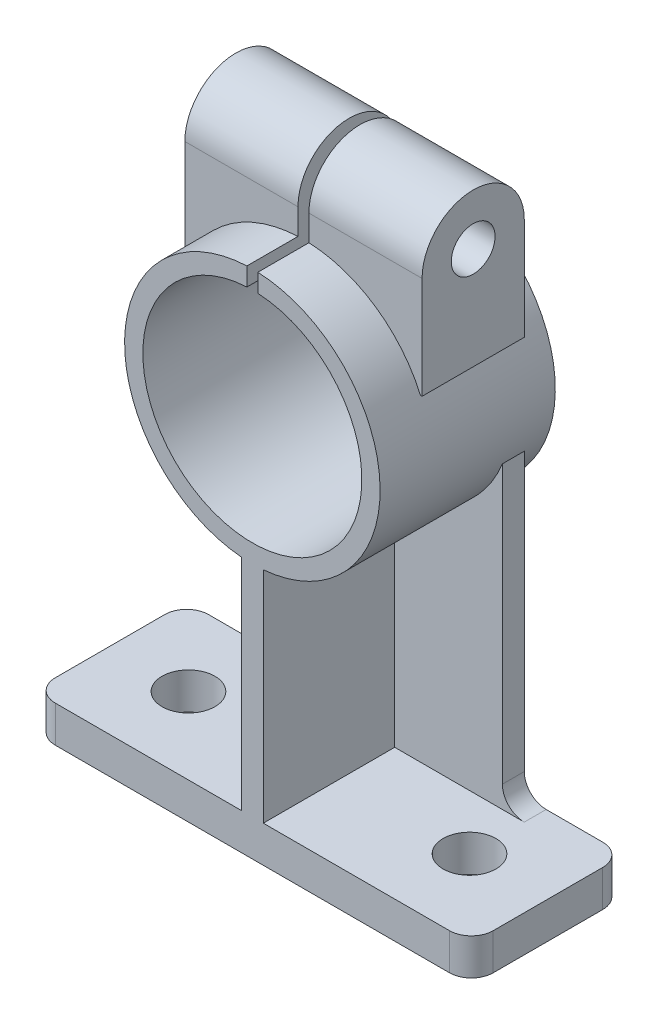
from build123d import *

# Parameters (mm, degrees)
CROQUIS2_W              = 120
CROQUIS2_H              = 42
SALIENTE_EXTRUIR1_DEPTH = 10
REDONDEO1_R             = 6
CROQUIS3_W              = 65
CROQUIS3_H              = 95
SALIENTE_EXTRUIR2_DEPTH = 6
REDONDEO2_R             = 6
CROQUIS4_R              = 7.240565909
CORTAR_EXTRUIR1_DEPTH   = 11
CROQUIS6_R              = 35
CROQUIS6_R_2            = 30
EXTRUIR_L_MINA1_DEPTH   = 48
CROQUIS8_W              = 6
CROQUIS8_H              = 60.128808452
SALIENTE_EXTRUIR3_DEPTH = 36
CROQUIS9_R              = 6
SALIENTE_EXTRUIR4_DEPTH = 32.5
CROQUIS10_R             = 30
CORTAR_EXTRUIR3_DEPTH   = 49
CROQUIS11_W             = 3
CROQUIS11_H             = 67.611732644
CORTAR_EXTRUIR4_DEPTH   = 49


with BuildPart() as part:
    # Croquis2 → Saliente-Extruir1 (new body)
    with BuildSketch(Plane(origin=(0, 0, 0), x_dir=(1, 0, 0), z_dir=(0, 1, 0))):
        with Locations((0, -21)):
            Rectangle(CROQUIS2_W, CROQUIS2_H)
    extrude(amount=SALIENTE_EXTRUIR1_DEPTH)

    # Redondeo1
    redondeo1_edges = [part.edges().sort_by_distance(p)[0] for p in [
        (60, 5, 42),
        (-60, 5, 42),
        (-60, 5, 0),
        (60, 5, 0),
    ]]
    fillet(redondeo1_edges, radius=REDONDEO1_R)

    # Croquis3 → Saliente-Extruir2 (add)
    with BuildSketch(Plane.XY):
        with Locations((0, 57.5)):
            Rectangle(CROQUIS3_W, CROQUIS3_H)
    extrude(amount=SALIENTE_EXTRUIR2_DEPTH)

    # Redondeo2
    redondeo2_edges = [part.edges().sort_by_distance(p)[0] for p in [
        (32.5, 10, 3),
        (-32.5, 10, 3),
    ]]
    fillet(redondeo2_edges, radius=REDONDEO2_R)

    # Croquis4 → Cortar-Extruir1 (cut, through all)
    with BuildSketch(Plane(origin=(0, 10, 0), x_dir=(1, 0, 0), z_dir=(0, 1, 0))):
        with Locations((-38.5, -21)):
            Circle(CROQUIS4_R)
    cortar_extruir1 = extrude(amount=-CORTAR_EXTRUIR1_DEPTH, mode=Mode.SUBTRACT)

    # Simetría1: Cortar-Extruir1 across plane
    add(cortar_extruir1.mirror(Plane(origin=(0, 0, 0), x_dir=(0, 0, 1), z_dir=(1, 0, 0))), mode=Mode.SUBTRACT)

    # Croquis6 → Extruir-Lámina1 (add)
    with BuildSketch(Plane.XY.offset(-6)):
        with Locations((0, 105)):
            Circle(CROQUIS6_R)
        with Locations((0, 105)):
            Circle(CROQUIS6_R_2, mode=Mode.SUBTRACT)
    extrude(amount=EXTRUIR_L_MINA1_DEPTH)

    # Croquis8 → Saliente-Extruir3 (add)
    with BuildSketch(Plane.XY.offset(6)):
        with Locations((0, 40.064404226)):
            Rectangle(CROQUIS8_W, CROQUIS8_H)
    extrude(amount=SALIENTE_EXTRUIR3_DEPTH)

    # Croquis9 → Saliente-Extruir4 (add, symmetric)
    with BuildSketch(Plane(origin=(0, 0, 0), x_dir=(0, 0, -1), z_dir=(1, 0, 0))):
        with BuildLine():
            Line((0, 126.068220277), (0, 147))
            ThreePointArc((0, 147), (-14, 161), (-28, 147))
            Line((-28, 147), (-28, 119.03405794))
            Line((-28, 119.03405794), (0, 119.03405794))
            Line((0, 119.03405794), (0, 126.068220277))
        make_face()
        with Locations((-14, 147)):
            Circle(CROQUIS9_R, mode=Mode.SUBTRACT)
    extrude(amount=SALIENTE_EXTRUIR4_DEPTH, both=True)

    # Croquis10 → Cortar-Extruir3 (cut, through all)
    with BuildSketch(Plane.XY.offset(-6)):
        with Locations((0, 105)):
            Circle(CROQUIS10_R)
    extrude(amount=CORTAR_EXTRUIR3_DEPTH, mode=Mode.SUBTRACT)

    # Croquis11 → Cortar-Extruir4 (cut, through all)
    with BuildSketch(Plane.XY.offset(-6)):
        with Locations((0, 138.805866322)):
            Rectangle(CROQUIS11_W, CROQUIS11_H)
    extrude(amount=CORTAR_EXTRUIR4_DEPTH, mode=Mode.SUBTRACT)


solid = part.part
